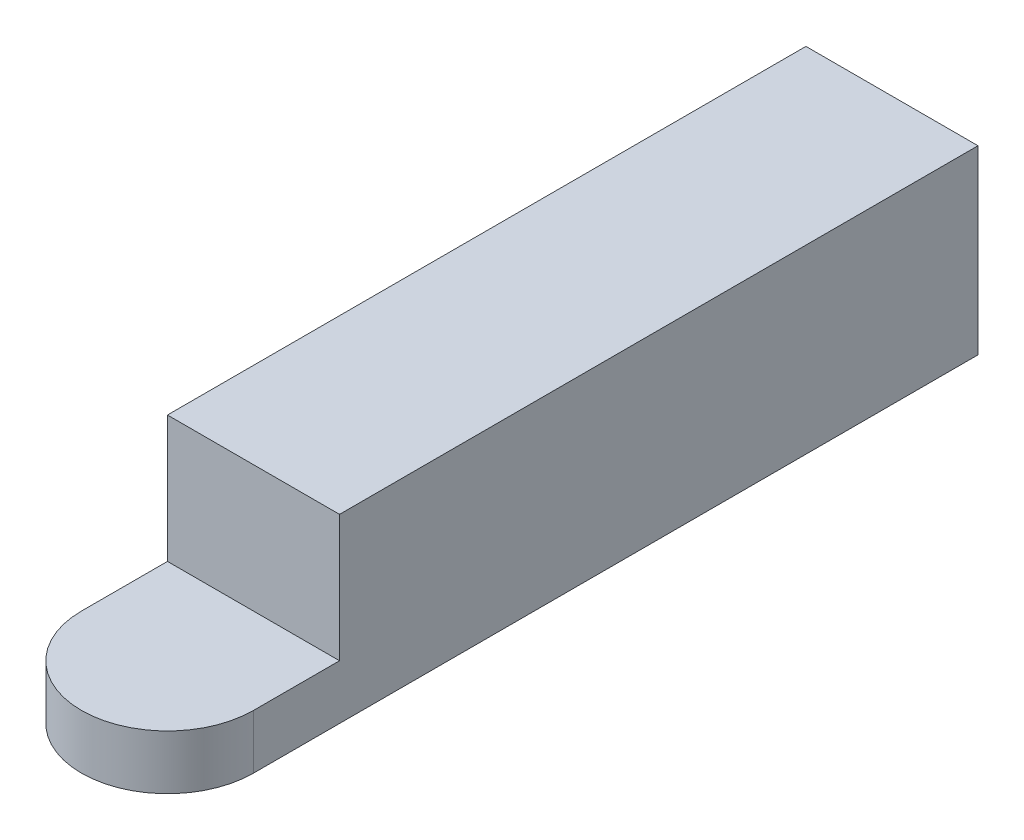
from build123d import *

# Parameters (mm, degrees)
SKETCH1_R           = 4.75
BOSS_EXTRUDE1_DEPTH = 3
BOSS_EXTRUDE2_DEPTH = 10
CUT_EXTRUDE1_DEPTH  = 7


with BuildPart() as part:
    # Sketch1 → Boss-Extrude1 (new body)
    with BuildSketch(Plane(origin=(0, 0, 0), x_dir=(1, 0, 0), z_dir=(0, 1, 0))):
        Circle(SKETCH1_R)
    extrude(amount=BOSS_EXTRUDE1_DEPTH)

    # Sketch2 → Boss-Extrude2 (add)
    with BuildSketch(Plane(origin=(0, 0, 0), x_dir=(1, 0, 0), z_dir=(0, 1, 0))):
        with BuildLine():
            Line((-4.75, 0), (-4.75, 40))
            Line((-4.75, 40), (4.75, 40))
            Line((4.75, 40), (4.75, 0))
            ThreePointArc((4.75, 0), (0, 4.75), (-4.75, 0))
        make_face()
    extrude(amount=BOSS_EXTRUDE2_DEPTH)

    # Sketch3 → Cut-Extrude1 (cut)
    with BuildSketch(Plane(origin=(0, 10, 0), x_dir=(1, 0, 0), z_dir=(0, 1, 0))):
        with BuildLine():
            ThreePointArc((-4.75, 0), (-3.358757211, 3.358757211), (0, 4.75))
            Line((0, 4.75), (-4.75, 4.75))
            Line((-4.75, 4.75), (-4.75, 0))
        make_face()
        with BuildLine():
            Line((4.75, 4.75), (0, 4.75))
            ThreePointArc((0, 4.75), (3.358757211, 3.358757211), (4.75, 0))
            Line((4.75, 0), (4.75, 4.75))
        make_face()
    extrude(amount=-CUT_EXTRUDE1_DEPTH, mode=Mode.SUBTRACT)


solid = part.part
